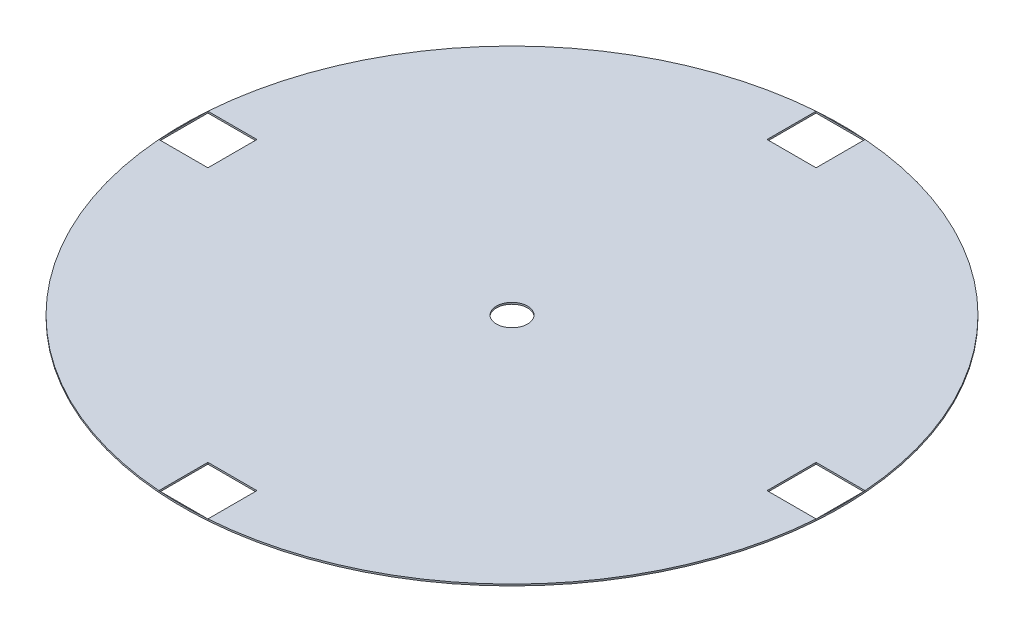
from build123d import *

# Parameters (mm, degrees)
CROQUIS1_R              = 403.28
CROQUIS1_R_2            = 19.05
SALIENTE_EXTRUIR1_DEPTH = 2
CROQUIS3_W              = 60
CROQUIS3_H              = 60
CORTAR_EXTRUIR1_DEPTH   = 3


with BuildPart() as part:
    # Croquis1 → Saliente-Extruir1 (new body)
    with BuildSketch(Plane(origin=(0, 0, 0), x_dir=(1, 0, 0), z_dir=(0, 1, 0))):
        Circle(CROQUIS1_R)
        Circle(CROQUIS1_R_2, mode=Mode.SUBTRACT)
    extrude(amount=SALIENTE_EXTRUIR1_DEPTH)

    # Croquis3 → Cortar-Extruir1 (cut, through all)
    with BuildSketch(Plane(origin=(0, 2, 0), x_dir=(1, 0, 0), z_dir=(0, 1, 0))):
        with Locations((372.162601941, 0)):
            Rectangle(CROQUIS3_W, CROQUIS3_H)
        with Locations((0, -372.162601941)):
            Rectangle(CROQUIS3_W, CROQUIS3_H)
        with Locations((-372.162601941, 0)):
            Rectangle(CROQUIS3_W, CROQUIS3_H)
        with Locations((0, 372.162601941)):
            Rectangle(CROQUIS3_W, CROQUIS3_H)
    extrude(amount=-CORTAR_EXTRUIR1_DEPTH, mode=Mode.SUBTRACT)


solid = part.part
